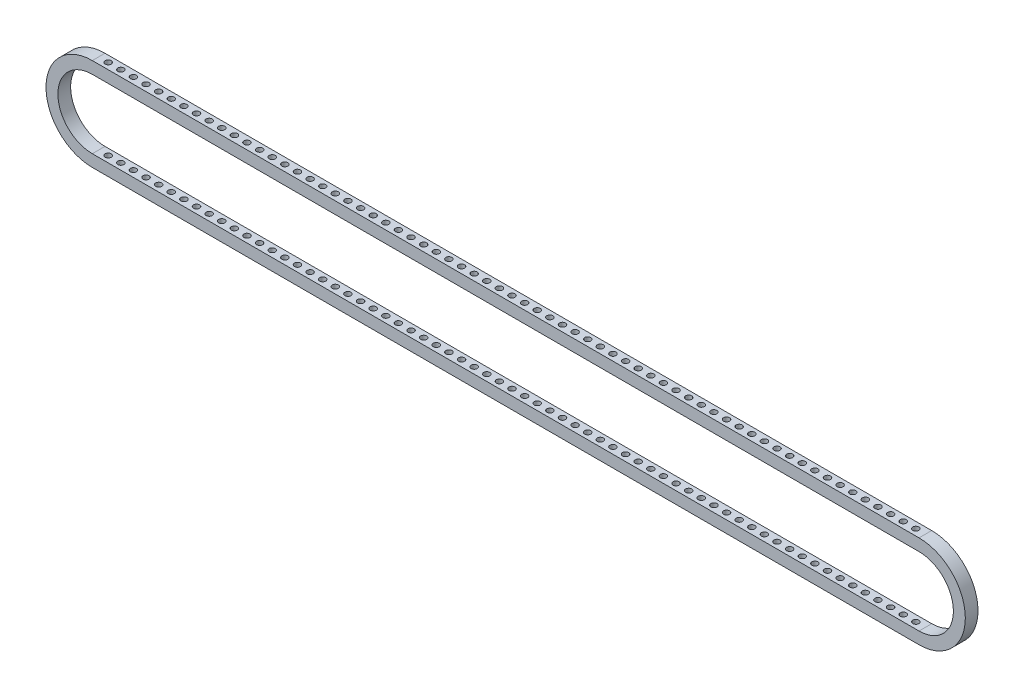
from build123d import *

# Parameters (mm, degrees)
EXTRUDE_1_DEPTH            = 3.19
CUT_EXTRUDE_START          = -47.59
SKETCH_2_R                 = 1.525
CUT_EXTRUDE_1_DEPTH        = 48.59
PATTERN_LINEAR_1_COUNT     = 33
PATTERN_LINEAR_1_PITCH     = 6.35
PATTERN_LINEAR_1_COL_COUNT = 33
PATTERN_LINEAR_1_COL_PITCH = 6.35


with BuildPart() as part:
    # 草图1 → 凸台-拉伸1 (new body, symmetric)
    with BuildSketch(Plane.XY):
        with BuildLine():
            Line((-208, 23.295), (208, 23.295))
            ThreePointArc((208, 23.295), (231.295, 0), (208, -23.295))
            Line((208, -23.295), (-208, -23.295))
            ThreePointArc((-208, -23.295), (-231.295, 0), (-208, 23.295))
        make_face()
        with BuildLine():
            Line((-208, 17.295), (208, 17.295))
            ThreePointArc((208, 17.295), (225.295, 0), (208, -17.295))
            Line((208, -17.295), (-208, -17.295))
            ThreePointArc((-208, -17.295), (-225.295, 0), (-208, 17.295))
        make_face(mode=Mode.SUBTRACT)
    extrude(amount=EXTRUDE_1_DEPTH, both=True)

    # 草图2 → 切除-拉伸1 (cut)
    with BuildSketch(Plane.XZ.offset(23.295).offset(CUT_EXTRUDE_START)):
        Circle(SKETCH_2_R)
    cut_extrude_1 = extrude(amount=CUT_EXTRUDE_1_DEPTH, mode=Mode.SUBTRACT)

    # 阵列(线性)1: 切除-拉伸1 ×33
    with Locations(*[(-i * PATTERN_LINEAR_1_PITCH, 0, 0) for i in range(1, PATTERN_LINEAR_1_COUNT)]):
        add(cut_extrude_1, mode=Mode.SUBTRACT)

    # 阵列(线性)1 col: 切除-拉伸1 ×33
    with Locations(*[(i * PATTERN_LINEAR_1_COL_PITCH, 0, 0) for i in range(1, PATTERN_LINEAR_1_COL_COUNT)]):
        add(cut_extrude_1, mode=Mode.SUBTRACT)


solid = part.part
